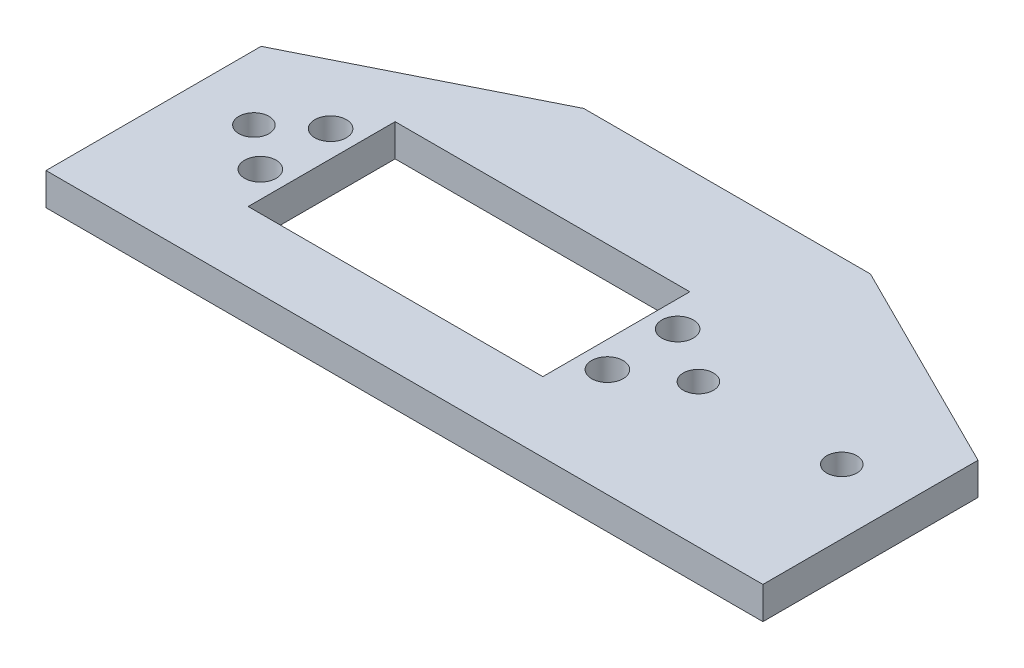
from build123d import *

# Parameters (mm, degrees)
SKETCH1_R           = 2.1
BOSS_EXTRUDE1_DEPTH = 4.5
SKETCH2_R           = 2.2
SKETCH2_W           = 41.1
SKETCH2_H           = 20.5
CUT_EXTRUDE1_DEPTH  = 10
SKETCH3_W           = 100
SKETCH3_H           = 20
CUT_EXTRUDE2_DEPTH  = 10


with BuildPart() as part:
    # Sketch1 → Boss-Extrude1 (new body)
    with BuildSketch(Plane(origin=(0, 0, 0), x_dir=(1, 0, 0), z_dir=(0, 1, 0))):
        Polygon((20, 40), (50, 25), (50, -25), (-50, -25), (-50, 25), (-20, 40), align=None)
        with Locations((-41, 15)):
            Circle(SKETCH1_R, mode=Mode.SUBTRACT)
        with Locations((41, 15)):
            Circle(SKETCH1_R, mode=Mode.SUBTRACT)
        with Locations((-21, 15)):
            Circle(SKETCH1_R, mode=Mode.SUBTRACT)
        with Locations((21, 15)):
            Circle(SKETCH1_R, mode=Mode.SUBTRACT)
    extrude(amount=BOSS_EXTRUDE1_DEPTH)

    # Sketch2 → Cut-Extrude1 (cut)
    with BuildSketch(Plane.XZ):
        with Locations((13.2, -19.9)):
            Circle(SKETCH2_R)
        with Locations((13.2, -10.1)):
            Circle(SKETCH2_R)
        with Locations((-35.2, -19.9)):
            Circle(SKETCH2_R)
        with Locations((-35.2, -10.1)):
            Circle(SKETCH2_R)
        with Locations((-11, -15)):
            Rectangle(SKETCH2_W, SKETCH2_H)
    extrude(amount=-CUT_EXTRUDE1_DEPTH, mode=Mode.SUBTRACT)

    # Sketch3 → Cut-Extrude2 (cut)
    with BuildSketch(Plane.XZ):
        with Locations((0, 15)):
            Rectangle(SKETCH3_W, SKETCH3_H)
    extrude(amount=-CUT_EXTRUDE2_DEPTH, mode=Mode.SUBTRACT)


solid = part.part
